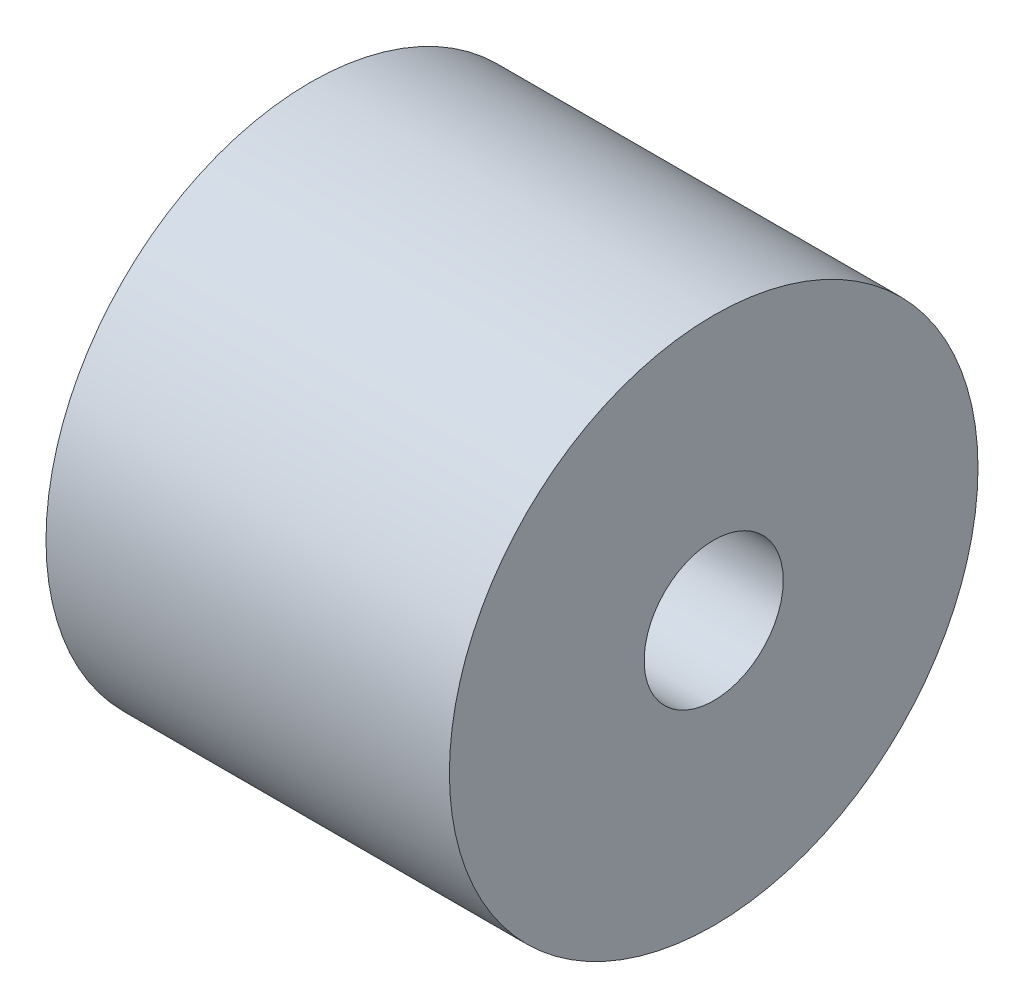
from build123d import *

# Parameters (mm, degrees)
SKETCH1_R                = 38
OUTERCIRCUMFERENCE_DEPTH = 58
SKETCH2_R                = 10
CUT_EXTRUDE2_DEPTH       = 59


with BuildPart() as part:
    # Sketch1 → OuterCircumference (new body)
    with BuildSketch(Plane(origin=(0, 0, 0), x_dir=(0, 0, -1), z_dir=(1, 0, 0))):
        Circle(SKETCH1_R)
    extrude(amount=OUTERCIRCUMFERENCE_DEPTH)

    # Sketch2 → Cut-Extrude2 (cut, through all)
    with BuildSketch(Plane(origin=(58, 0, 0), x_dir=(0, 0, -1), z_dir=(1, 0, 0))):
        Circle(SKETCH2_R)
    extrude(amount=-CUT_EXTRUDE2_DEPTH, mode=Mode.SUBTRACT)


solid = part.part
